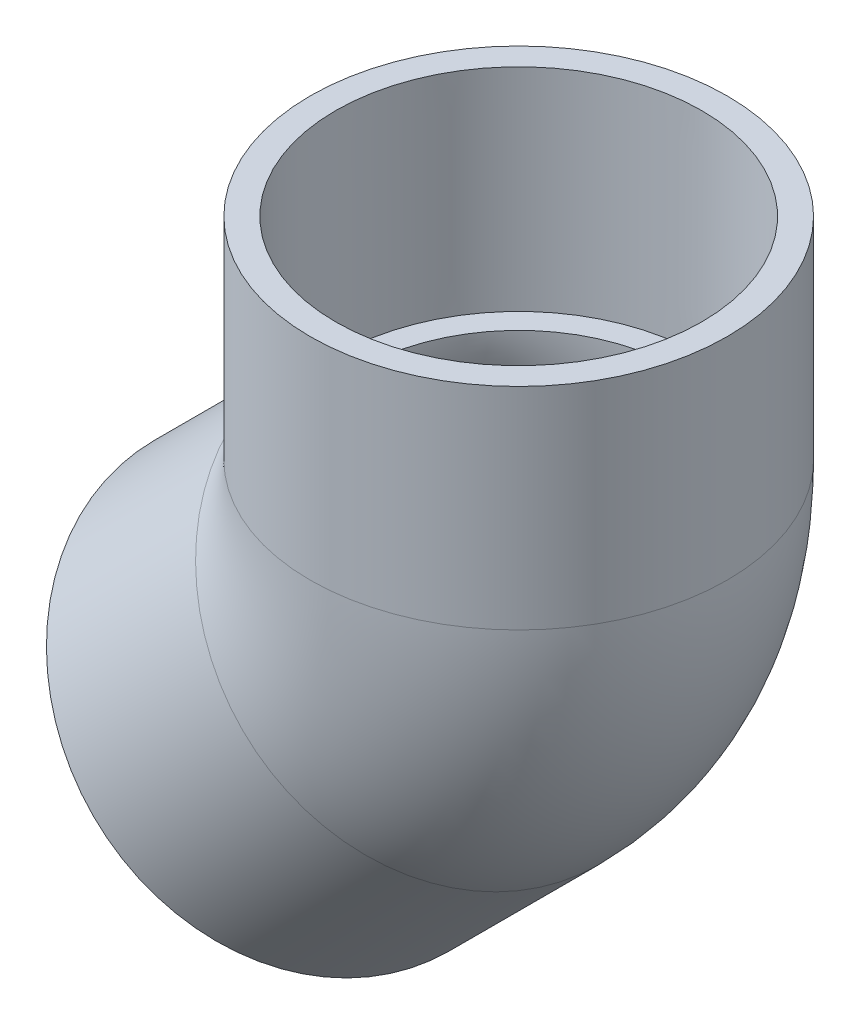
from build123d import *

# Parameters (mm, degrees)
SKETCH3_R   = 34.528125
SKETCH3_R_2 = 26.2509


with BuildPart() as part:
    # Sketch1 → Revolve1 (revolve)
    with BuildSketch(Plane.XY):
        Polygon((-11.505953155, -60.336095813), (13.189751178, -35.64039148), (10.048906599, -32.499546902), (-14.485153123, -57.356895845), align=None)
    revolve(axis=Axis((-35.921024484, -35.921024484, 0), (0.7071067811865486, 0.7071067811865465, 0)))



with BuildPart() as body_2:
    # Sketch2 → Revolve2 (revolve)
    with BuildSketch(Plane.XY):
        Polygon((30.3149, 50.8), (30.0863, 15.875), (34.528125, 15.875), (34.528125, 50.8), align=None)
    revolve(axis=Axis((0, 0, 0), (0, 1, 0)))


with BuildPart() as part_1:
    add(part.part)

    add(body_2.part)  # Sweep1 merges body 2
    # Sweep1: sweep along a path in Sketch4
    with BuildLine(Plane.XY) as sweep1_path:
        ThreePointArc((-11.225320151, -11.225320151), (-2.917365657, 1.208412421), (0, 15.875))
    # Sketch3 → Sweep1 (sweep)
    with BuildSketch(Plane(origin=(-11.225320151, -11.225320151, 0), x_dir=(0, 0, -1), z_dir=(0.7071067811865488, 0.7071067811865464, 0))):
        Circle(SKETCH3_R)
        Circle(SKETCH3_R_2, mode=Mode.SUBTRACT)
    sweep(path=sweep1_path.line)


solid = part_1.part
